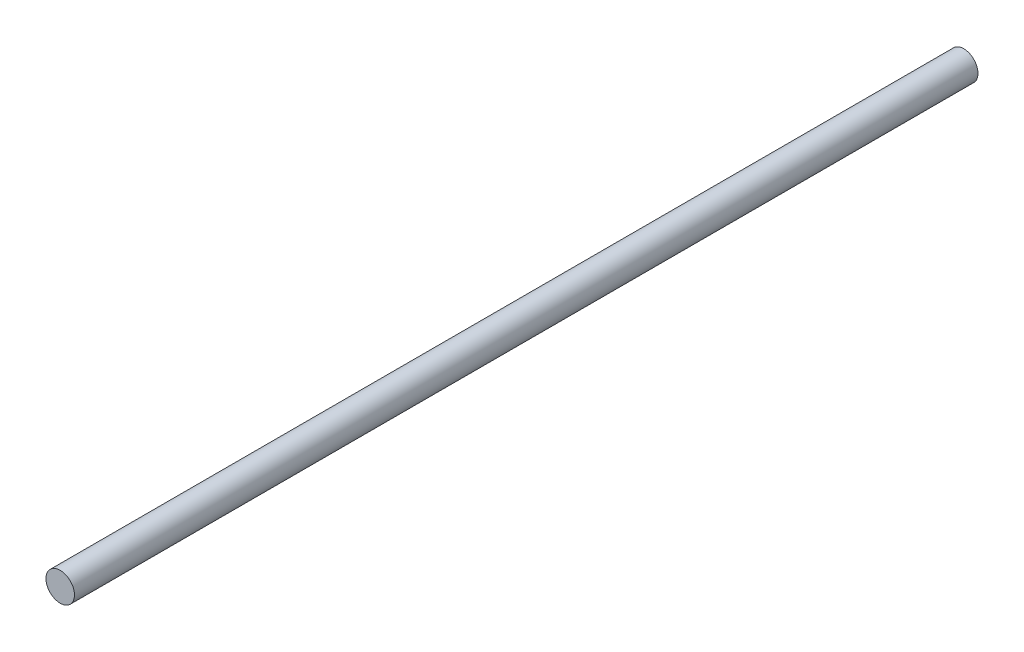
from build123d import *

# Parameters (mm, degrees)
IZIM1_R                     = 3.975
Y_KSEKLIK_EKSTR_ZYON1_DEPTH = 252


with BuildPart() as part:
    # Çizim1 → Yükseklik-Ekstrüzyon1 (new body)
    with BuildSketch(Plane.XY):
        Circle(IZIM1_R)
    extrude(amount=Y_KSEKLIK_EKSTR_ZYON1_DEPTH)


solid = part.part
